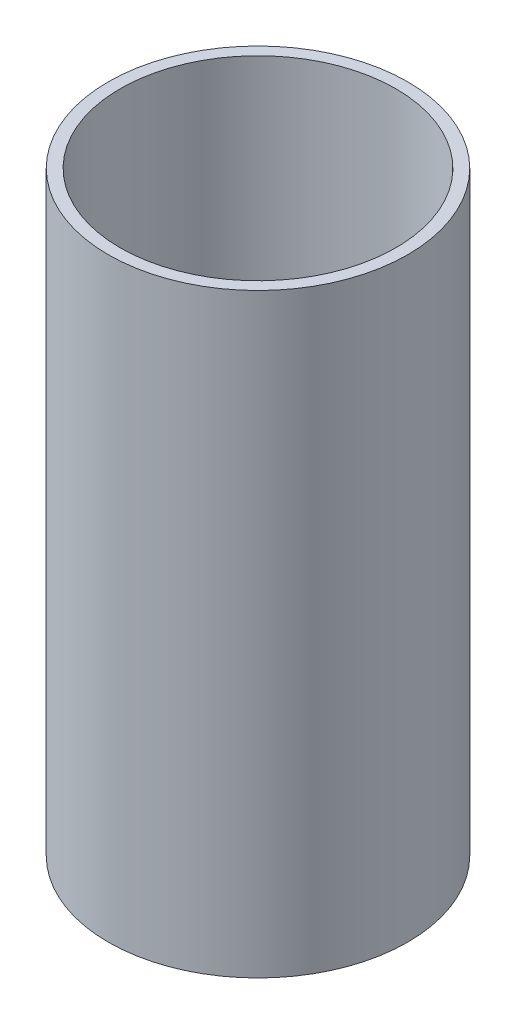
from build123d import *

# Parameters (mm, degrees)
SKETCH1_R           = 25.15
SKETCH1_R_2         = 23.15
BOSS_EXTRUDE1_DEPTH = 100
SKETCH2_R           = 25.15
BOSS_EXTRUDE2_DEPTH = 3


with BuildPart() as part:
    # Sketch1 → Boss-Extrude1 (new body)
    with BuildSketch(Plane(origin=(0, 0, 0), x_dir=(1, 0, 0), z_dir=(0, 1, 0))):
        Circle(SKETCH1_R)
        Circle(SKETCH1_R_2, mode=Mode.SUBTRACT)
    extrude(amount=BOSS_EXTRUDE1_DEPTH)

    # Sketch2 → Boss-Extrude2 (add)
    with BuildSketch(Plane.XZ):
        Circle(SKETCH2_R)
    extrude(amount=-BOSS_EXTRUDE2_DEPTH)


solid = part.part
